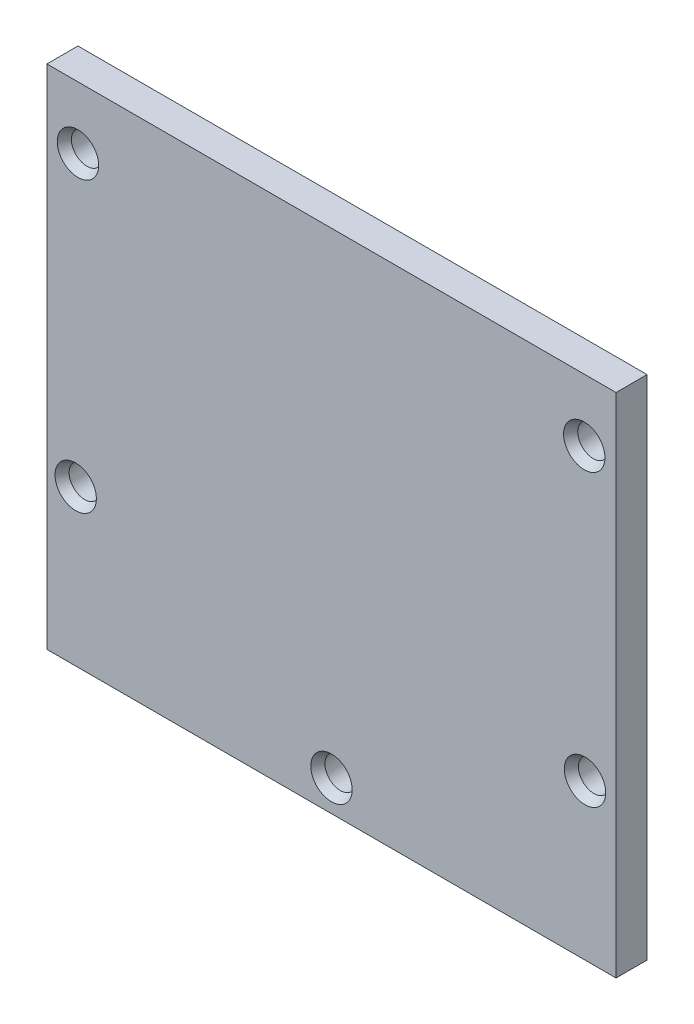
from build123d import *

# Parameters (mm, degrees)
SKETCH_1_W      = 55
SKETCH_1_H      = 49
SKETCH_1_R      = 1.5
EXTRUDE_1_DEPTH = 3
CHAMFER_1_SIZE  = 0.5
CHAMFER_1_SIZE2 = 0.866025404


with BuildPart() as part:
    # Эскиз1 → Бобышка-Вытянуть1 (new body)
    with BuildSketch(Plane.XY):
        with Locations((0, -3)):
            Rectangle(SKETCH_1_W, SKETCH_1_H)
        with Locations((-24.5, 15.5)):
            Circle(SKETCH_1_R, mode=Mode.SUBTRACT)
        with Locations((-24.71865387, -12.5)):
            Circle(SKETCH_1_R, mode=Mode.SUBTRACT)
        with Locations((24.5, -12.5)):
            Circle(SKETCH_1_R, mode=Mode.SUBTRACT)
        with Locations((24.430350012, 15.5)):
            Circle(SKETCH_1_R, mode=Mode.SUBTRACT)
        with Locations((0, -24.5)):
            Circle(SKETCH_1_R, mode=Mode.SUBTRACT)
    extrude(amount=EXTRUDE_1_DEPTH)

    # Фаска1
    chamfer_1_edges = [part.edges().sort_by_distance(p)[0] for p in [
        (-26, 15.5, 3),
        (-26.21865387, -12.5, 3),
        (23, -12.5, 3),
        (22.930350012, 15.5, 3),
        (-1.5, -24.5, 3),
    ]]
    chamfer_1_side = [part.faces().sort_by_distance(p)[0] for p in [
        (0.000766227, -2.990698033, 3),
    ]]
    chamfer(chamfer_1_edges, length=CHAMFER_1_SIZE, length2=CHAMFER_1_SIZE2, reference=chamfer_1_side[0])


solid = part.part
